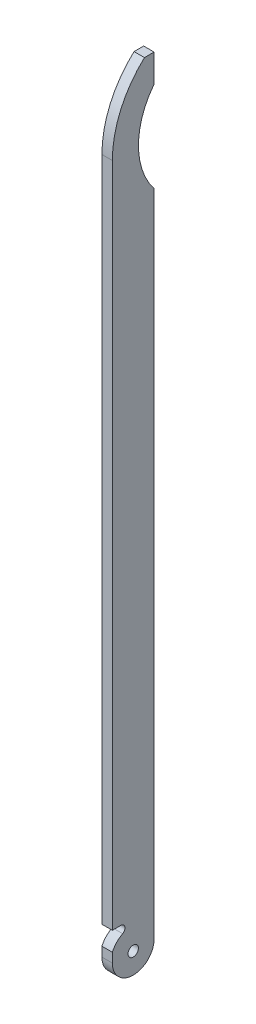
from build123d import *

# Parameters (mm, degrees)
SKETCH_1_W          = 5
SKETCH_1_H          = 20
EXTRUDE_1_DEPTH     = 378
CUT_EXTRUDE_1_DEPTH = 6
SKETCH_3_R          = 2.5
CUT_EXTRUDE_2_DEPTH = 6
SKETCH_4_R          = 35
CUT_EXTRUDE_3_DEPTH = 6
CUT_EXTRUDE_4_DEPTH = 6
CUT_EXTRUDE_5_DEPTH = 6


with BuildPart() as part:
    # Эскиз1 → Бобышка-Вытянуть1 (new body)
    with BuildSketch(Plane(origin=(0, 0, 0), x_dir=(1, 0, 0), z_dir=(0, 1, 0))):
        with Locations((2.5, -10)):
            Rectangle(SKETCH_1_W, SKETCH_1_H)
    extrude(amount=EXTRUDE_1_DEPTH)

    # Эскиз2 → Вырез-Вытянуть1 (cut, through all)
    with BuildSketch(Plane.ZY):
        with BuildLine():
            Line((0, 10), (0, -2))
            Line((0, -2), (20, -2))
            Line((20, -2), (20, 10))
            ThreePointArc((20, 10), (10, 0), (0, 10))
        make_face()
    extrude(amount=-CUT_EXTRUDE_1_DEPTH, mode=Mode.SUBTRACT)

    # Эскиз3 → Вырез-Вытянуть2 (cut, through all)
    with BuildSketch(Plane.ZY):
        with Locations((10, 10)):
            Circle(SKETCH_3_R)
    extrude(amount=-CUT_EXTRUDE_2_DEPTH, mode=Mode.SUBTRACT)

    # Эскиз4 → Вырез-Вытянуть3 (cut, through all)
    with BuildSketch(Plane.ZY):
        with Locations((-27.5, 343)):
            Circle(SKETCH_4_R)
    extrude(amount=-CUT_EXTRUDE_3_DEPTH, mode=Mode.SUBTRACT)

    # Эскиз5 → Вырез-Вытянуть4 (cut, through all)
    with BuildSketch(Plane.ZY):
        with BuildLine():
            Line((0, 381.729833462), (20, 378))
            Line((20, 378), (20, 343))
            ThreePointArc((20, 343), (14.70485754, 364.794494718), (0, 381.729833462))
        make_face()
    extrude(amount=-CUT_EXTRUDE_4_DEPTH, mode=Mode.SUBTRACT)

    # Эскиз6 → Вырез-Вытянуть5 (cut, through all)
    with BuildSketch(Plane(origin=(5, 0, 0), x_dir=(0, 0, -1), z_dir=(1, 0, 0))):
        with BuildLine():
            Line((-16, 23.61), (-20, 23.61))
            Line((-20, 23.61), (-20, 19.51))
            Line((-20, 19.51), (-20, 14.520650354))
            ThreePointArc((-20, 14.520650354), (-17.967405564, 17.546968146), (-15.055614801, 19.740484516))
            ThreePointArc((-15.055614801, 19.740484516), (-14.008454527, 22.046052085), (-16, 23.61))
        make_face()
    extrude(amount=-CUT_EXTRUDE_5_DEPTH, mode=Mode.SUBTRACT)


solid = part.part
